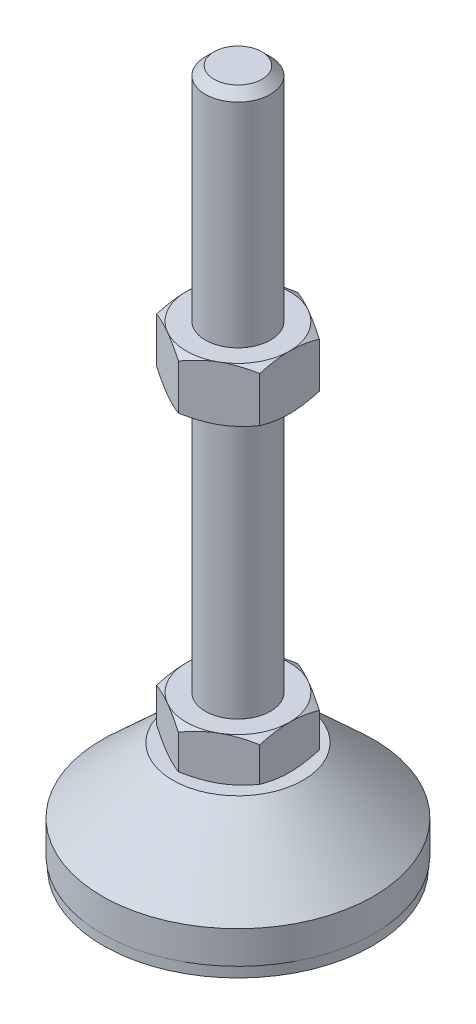
from build123d import *

# Parameters (mm, degrees)
EXTRUDE_1_DEPTH = 8
EXTRUDE_2_DEPTH = 10


with BuildPart() as part:
    # Эскиз1 → Повернуть1 (revolve)
    with BuildSketch(Plane.XY, mode=Mode.PRIVATE) as revolve_1_sk:
        Polygon((0, 0), (-24.8, 0), (-24.8, 2), (-25, 2), (-25, 8), (-12, 20), (-6, 20), (-6, 28), (-6, 126.4), (-4.4, 128), (0, 128), align=None)
    revolve(revolve_1_sk.sketch.rotate(Axis((0, 0, 0), (0, 1, 0)), 180), axis=Axis((0, 0, 0), (0, 1, 0)))  # turned: the seam where the file's is

    # Эскиз2 → Бобышка-Вытянуть1 (add)
    with BuildSketch(Plane(origin=(0, 20, 0), x_dir=(1, 0, 0), z_dir=(0, 1, 0))):
        Polygon((0, 10.969655115), (-9.5, 5.484827557), (-9.5, -5.484827557), (0, -10.969655115), (9.5, -5.484827557), (9.5, 5.484827557), align=None)
    extrude(amount=EXTRUDE_1_DEPTH)

    # Эскиз3 → Бобышка-Вытянуть2 (add)
    with BuildSketch(Plane(origin=(0, 77.2, 0), x_dir=(1, 0, 0), z_dir=(0, 1, 0))):
        Polygon((9.5, 5.484827557), (0, 10.969655115), (-9.5, 5.484827557), (-9.5, -5.484827557), (0, -10.969655115), (9.5, -5.484827557), align=None)
    extrude(amount=EXTRUDE_2_DEPTH)

    # Эскиз4 → Вырез-Повернуть2 (revolve, cut)
    with BuildSketch(Plane.XY, mode=Mode.PRIVATE) as cut_revolve_2_sk:
        Polygon((-18.160254038, 87.2), (-9.5, 87.2), (-18.160254038, 82.2), align=None)
        Polygon((-18.160254038, 77.2), (-18.160254038, 82.2), (-9.5, 77.2), align=None)
        Polygon((-16.42820323, 28), (-16.42820323, 24), (-9.5, 28), align=None)
        Polygon((-16.42820323, 24), (-16.42820323, 20), (-9.5, 20), align=None)
    revolve(cut_revolve_2_sk.sketch.rotate(Axis((0, 128, 0), (0, -1, 0)), 180), axis=Axis((0, 128, 0), (0, -1, 0)), mode=Mode.SUBTRACT)  # turned: the seam where the file's is


solid = part.part
